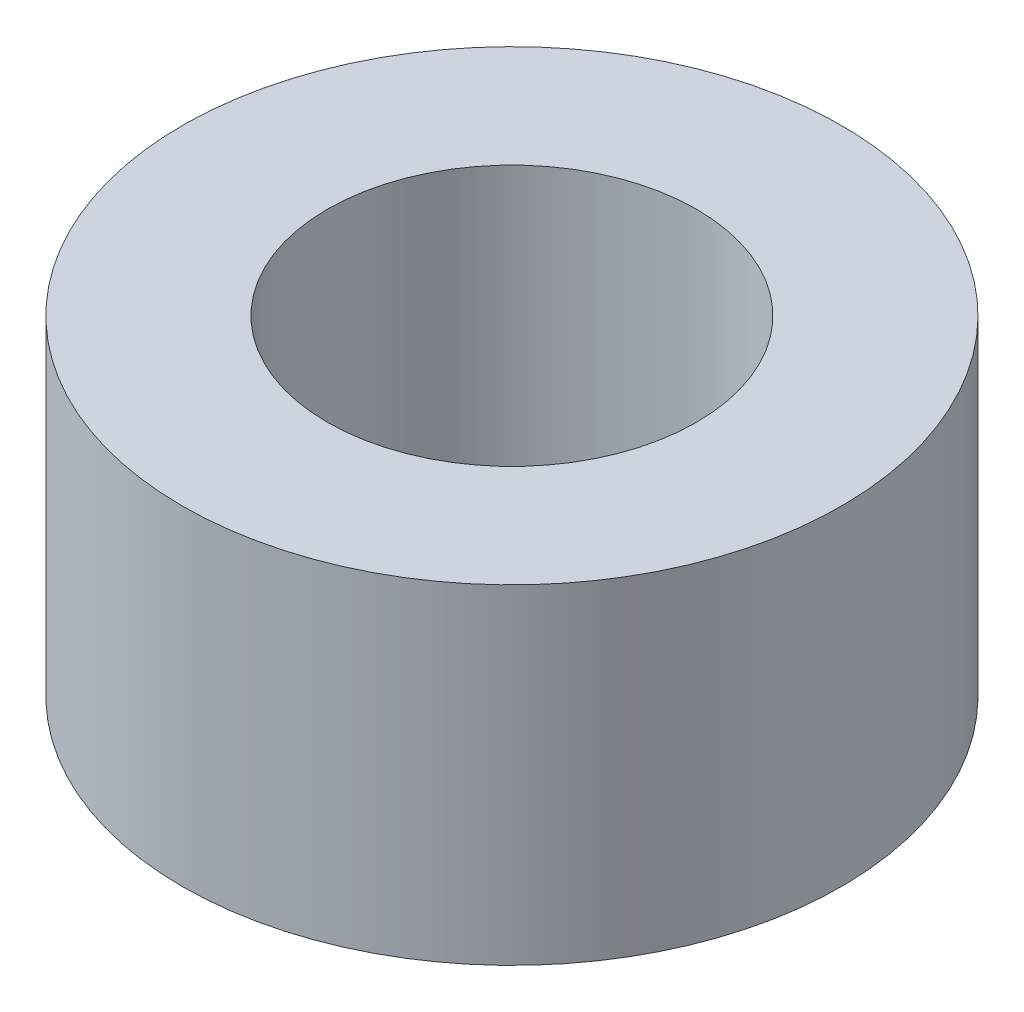
from build123d import *

# Parameters (mm, degrees)
SKETCH1_R           = 3.175
BOSS_EXTRUDE1_DEPTH = 3.175
SKETCH2_R           = 1.778
CUT_EXTRUDE1_DEPTH  = 4.175


with BuildPart() as part:
    # Sketch1 → Boss-Extrude1 (new body)
    with BuildSketch(Plane(origin=(0, 0, 0), x_dir=(1, 0, 0), z_dir=(0, 1, 0))):
        Circle(SKETCH1_R)
    extrude(amount=BOSS_EXTRUDE1_DEPTH)

    # Sketch2 → Cut-Extrude1 (cut, through all)
    with BuildSketch(Plane(origin=(0, 3.175, 0), x_dir=(1, 0, 0), z_dir=(0, 1, 0))):
        Circle(SKETCH2_R)
    extrude(amount=-CUT_EXTRUDE1_DEPTH, mode=Mode.SUBTRACT)


solid = part.part
